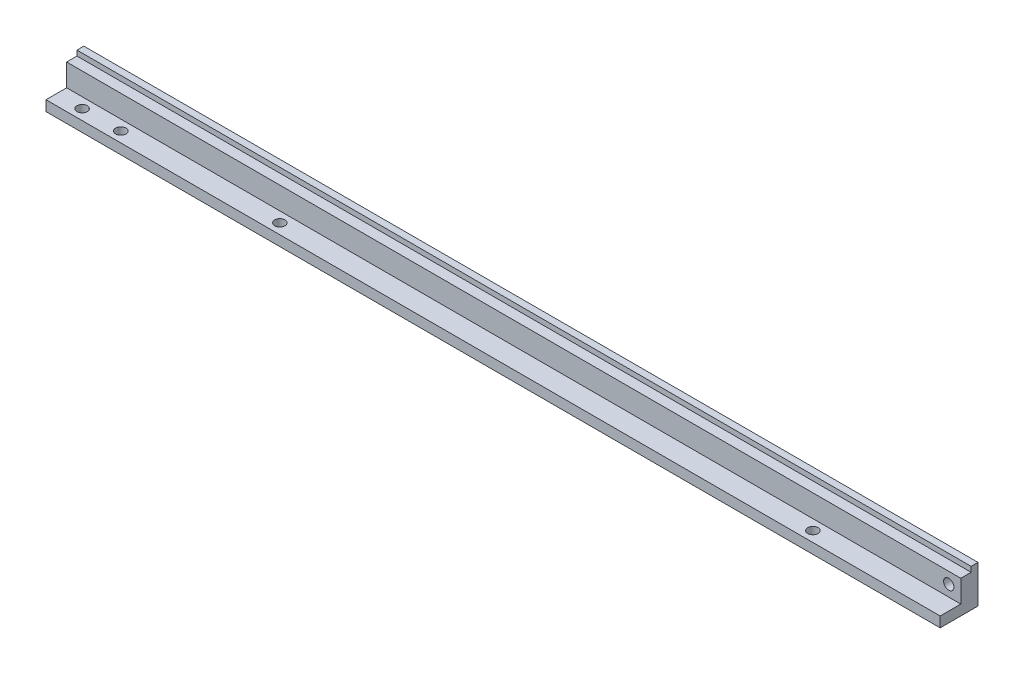
from build123d import *

# Parameters (mm, degrees)
EXTRUDE_1_DEPTH     = 260
SKETCH_2_R          = 1.5
CUT_EXTRUDE_1_DEPTH = 6
SKETCH_3_R          = 1.5
CUT_EXTRUDE_2_DEPTH = 4
SKETCH_5_R          = 1.5
CUT_EXTRUDE_4_DEPTH = 4


with BuildPart() as part:
    # Эскиз1 → Бобышка-Вытянуть1 (new body)
    with BuildSketch(Plane(origin=(0, 0, 0), x_dir=(0, 0, -1), z_dir=(1, 0, 0))):
        Polygon((0, 0), (-11, 0), (-11, 3), (-5, 3), (-5, 9.5), (-2, 9.5), (-2, 11), (0, 11), align=None)
    extrude(amount=EXTRUDE_1_DEPTH)

    # Эскиз2 → Вырез-Вытянуть1 (cut, through all)
    with BuildSketch(Plane.XY.offset(5)):
        with Locations((256.5, 6.25)):
            Circle(SKETCH_2_R)
    extrude(amount=-CUT_EXTRUDE_1_DEPTH, mode=Mode.SUBTRACT)

    # Эскиз3 → Вырез-Вытянуть2 (cut, through all)
    with BuildSketch(Plane(origin=(0, 3, 0), x_dir=(1, 0, 0), z_dir=(0, 1, 0))):
        with Locations((7.5, -8)):
            Circle(SKETCH_3_R)
        with Locations((18.75, -8)):
            Circle(SKETCH_3_R)
    extrude(amount=-CUT_EXTRUDE_2_DEPTH, mode=Mode.SUBTRACT)

    # Эскиз5 → Вырез-Вытянуть4 (cut, through all)
    with BuildSketch(Plane(origin=(0, 3, 0), x_dir=(1, 0, 0), z_dir=(0, 1, 0))):
        with Locations((65, -8)):
            Circle(SKETCH_5_R)
        with Locations((220, -8)):
            Circle(SKETCH_5_R)
    extrude(amount=-CUT_EXTRUDE_4_DEPTH, mode=Mode.SUBTRACT)


solid = part.part
